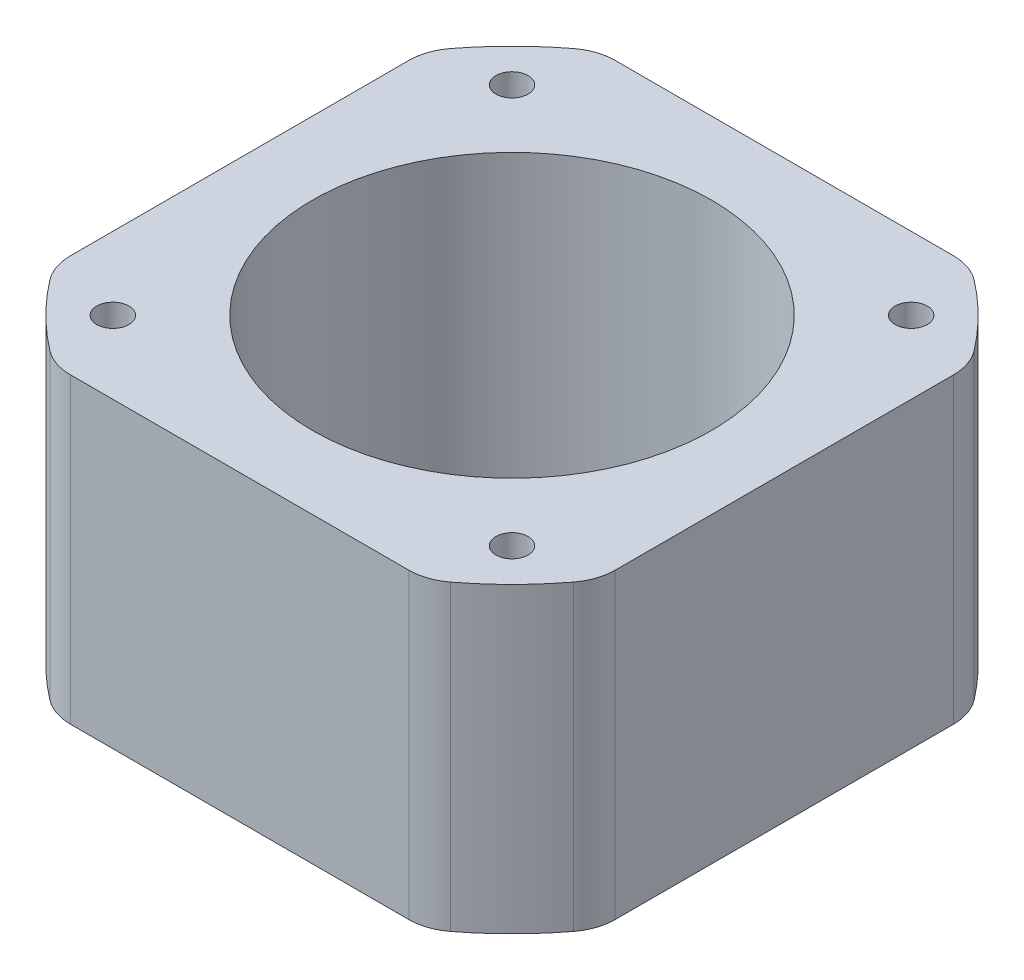
from build123d import *

# Parameters (mm, degrees)
SKETCH_1_R      = 1.25
SKETCH_1_R_2    = 15.5
EXTRUDE_1_DEPTH = 23.5
FILLET_1_R      = 4


with BuildPart() as part:
    # Эскиз1 → Бобышка-Вытянуть1 (new body)
    with BuildSketch(Plane(origin=(0, 0, 0), x_dir=(1, 0, 0), z_dir=(0, 1, 0))):
        with BuildLine():
            Line((-14.423505122, -21.15), (14.423505122, -21.15))
            ThreePointArc((14.423505122, -21.15), (18.101933598, -18.101933598), (21.15, -14.423505122))
            Line((21.15, -14.423505122), (21.15, 14.423505122))
            ThreePointArc((21.15, 14.423505122), (18.101933598, 18.101933598), (14.423505122, 21.15))
            Line((14.423505122, 21.15), (-14.423505122, 21.15))
            ThreePointArc((-14.423505122, 21.15), (-18.101933598, 18.101933598), (-21.15, 14.423505122))
            Line((-21.15, 14.423505122), (-21.15, -14.423505122))
            ThreePointArc((-21.15, -14.423505122), (-18.101933598, -18.101933598), (-14.423505122, -21.15))
        make_face()
        with Locations((-15.5, 15.5)):
            Circle(SKETCH_1_R, mode=Mode.SUBTRACT)
        with Locations((15.5, 15.5)):
            Circle(SKETCH_1_R, mode=Mode.SUBTRACT)
        with Locations((15.5, -15.5)):
            Circle(SKETCH_1_R, mode=Mode.SUBTRACT)
        with Locations((-15.5, -15.5)):
            Circle(SKETCH_1_R, mode=Mode.SUBTRACT)
        Circle(SKETCH_1_R_2, mode=Mode.SUBTRACT)
    extrude(amount=EXTRUDE_1_DEPTH)

    # Скругление1
    fillet_1_edges = [part.edges().sort_by_distance(p)[0] for p in [
        (21.15, 11.75, -14.423505122),
        (21.15, 11.75, 14.423505122),
        (14.423505122, 11.75, 21.15),
        (-14.423505122, 11.75, 21.15),
        (-21.15, 11.75, 14.423505122),
        (-21.15, 11.75, -14.423505122),
        (-14.423505122, 11.75, -21.15),
        (14.423505122, 11.75, -21.15),
    ]]
    fillet(fillet_1_edges, radius=FILLET_1_R)


solid = part.part
